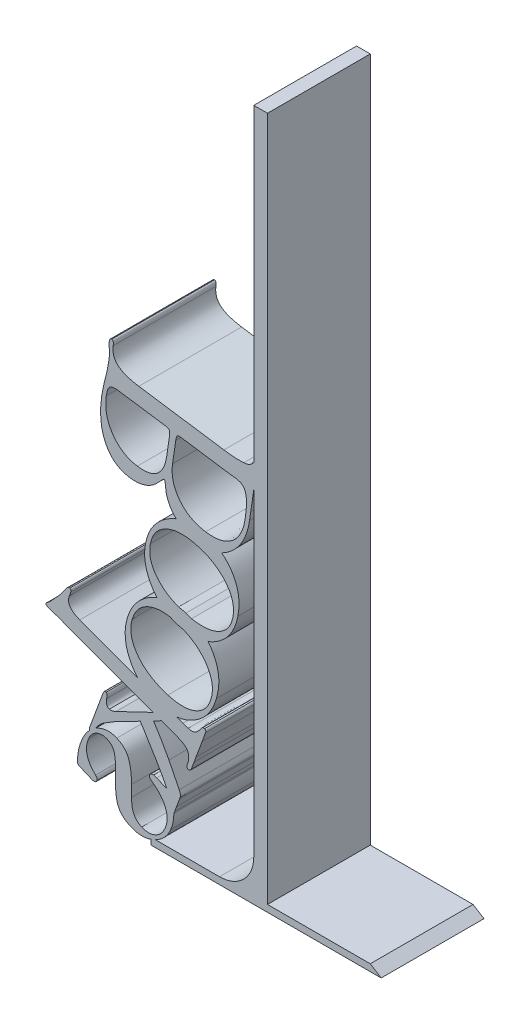
from build123d import *

# Parameters (mm, degrees)
BOSS_EXTRU_1_DEPTH = 30
BOSS_EXTRU_2_DEPTH = 30
CONG_1_R           = 10


with BuildPart() as part:
    # Esquisse1 → Boss.-Extru.1 (new body)
    with BuildSketch(Plane.XY):
        Polygon((0, 0), (37.189024069, 0), (34, 2), (4, 2), (4, 202), (0, 202), (0, 2), (-30, 2), (-30, 0), align=None)
    extrude(amount=BOSS_EXTRU_1_DEPTH)

    # Esquisse3 → Boss.-Extru.2 (add)
    # profile 1 of 5: a face of its own
    with BuildSketch(Plane.XY):
        with BuildLine():
            add(Edge.make_bspline(
                [(-50.119999035, 16.68534549), (-50.282082733, 16.293399286), (-50.595925094, 15.534474581), (-50.938660564, 14.394068336), (-51.203113741, 13.31291377), (-51.286389448, 12.602862585), (-51.326645377, 12.259619995)],
                knots=[0, 0, 0, 0, 1.104514137, 2.138668663, 3.100222345, 4, 4, 4, 4], degree=3))
            Line((-51.326645377, 12.259619995), (-51.501027505, 10.736615205))
            add(Edge.make_bspline(
                [(-51.501027505, 10.736615205), (-51.504554326, 10.592889791), (-51.510980035, 10.331028577), (-51.435333427, 9.973711105), (-51.264410087, 9.695330692), (-51.09112563, 9.596303894), (-51.005850834, 9.54757194)],
                knots=[0, 0, 0, 0, 1.251937487, 2.280973562, 3.154052059, 4, 4, 4, 4], degree=3))
            Line((-51.005850834, 9.54757194), (-50.517964503, 9.346357629))
            add(Edge.make_bspline(
                [(-50.517964503, 9.346357629), (-50.380045017, 9.285943004), (-50.10041353, 9.163452471), (-49.818764175, 9.045675312), (-49.676029556, 8.985988054)],
                knots=[0, 0, 0, 0, 0.986437454, 2, 2, 2, 2], degree=3))
            Line((-49.676029556, 8.985988054), (-48.499937878, 8.486880165))
            add(Edge.make_bspline(
                [(-48.499937878, 8.486880165), (-48.299790457, 8.39848823), (-47.920452322, 8.230959557), (-47.538007585, 8.070653097), (-47.357349383, 7.994927968)],
                knots=[0, 0, 0, 0, 1.055245452, 2, 2, 2, 2], degree=3))
            add(Edge.make_bspline(
                [(-47.357349383, 7.994927968), (-47.179889274, 7.930174771), (-46.863267099, 7.814642901), (-46.37656504, 7.798430686), (-45.981561775, 8.022529158), (-45.835921531, 8.268562161), (-45.759637283, 8.39743068)],
                knots=[0, 0, 0, 0, 1.219013251, 2.174948671, 3.04406458, 4, 4, 4, 4], degree=3))
            add(Edge.make_bspline(
                [(-45.759637283, 8.39743068), (-45.729953475, 8.48391235), (-45.668561112, 8.662774648), (-45.745872642, 8.974150701), (-45.900986107, 9.310633299), (-46.077124366, 9.522983942), (-46.173496201, 9.639168928)],
                knots=[0, 0, 0, 0, 0.780026984, 1.613259994, 2.694125199, 4, 4, 4, 4], degree=3))
            add(Edge.make_bspline(
                [(-46.173496201, 9.639168928), (-46.482738582, 9.939793105), (-47.076274753, 10.516788156), (-47.798191148, 11.479954186), (-48.341613787, 12.466629019), (-48.692232883, 13.489868271), (-48.855669751, 14.542814144), (-48.832648893, 15.62420075), (-48.619749287, 16.733942014), (-48.345410588, 17.451808786), (-48.203626365, 17.82281799)],
                knots=[0, 0, 0, 0, 1.138726599, 2.185584729, 3.168938811, 4.105254725, 5.029930041, 5.971323709, 6.951535848, 8, 8, 8, 8], degree=3))
            add(Edge.make_bspline(
                [(-48.203626365, 17.82281799), (-48.068498438, 18.106484848), (-47.807675032, 18.654017524), (-47.267979095, 19.365288265), (-46.640072106, 19.948703016), (-45.91423927, 20.363796437), (-45.148015441, 20.651258508), (-44.349081637, 20.723201047), (-43.539152222, 20.667268301), (-43.030226056, 20.472727846), (-42.76811349, 20.372533552)],
                knots=[0, 0, 0, 0, 1.119556932, 2.160964479, 3.168212037, 4.158551389, 5.130241561, 6.064749018, 7.003286457, 8, 8, 8, 8], degree=3))
            add(Edge.make_bspline(
                [(-42.76811349, 20.372533552), (-42.50355616, 20.24140882), (-41.987763201, 19.985762101), (-41.366554473, 19.375417489), (-40.900718948, 18.632328609), (-40.663313823, 17.894947979), (-40.553822271, 17.222711755), (-40.45894146, 16.629484244), (-40.413715389, 15.954076742), (-40.346128469, 15.202129167), (-40.321973611, 14.369744564), (-40.320005929, 13.460108764), (-40.3032265, 12.472265334), (-40.321674865, 11.787042299), (-40.331259913, 11.431027265)],
                knots=[0, 0, 0, 0, 1.073847664, 2.093622063, 3.13628929, 4.255159849, 4.897600423, 5.62733423, 6.450362783, 7.371228827, 8.387907505, 9.493754878, 10.697853257, 12, 12, 12, 12], degree=3))
            add(Edge.make_bspline(
                [(-40.331259913, 11.431027265), (-40.340562173, 11.079501855), (-40.358518013, 10.400964174), (-40.344342378, 9.419041524), (-40.296836897, 8.506006031), (-40.215509863, 7.661645265), (-40.100858472, 6.882876856), (-39.943687692, 6.175575059), (-39.748615816, 5.538651635), (-39.461000817, 4.77840835), (-38.949449273, 3.919721319), (-38.122834137, 3.026533204), (-37.086993241, 2.251003784), (-36.2821333, 1.878136125), (-35.862243347, 1.683613605)],
                knots=[0, 0, 0, 0, 1.091810361, 2.107484833, 3.048367522, 3.929971846, 4.740530701, 5.491118865, 6.177284609, 6.807462583, 8.012022279, 9.25179771, 10.566281569, 12, 12, 12, 12], degree=3))
            add(Edge.make_bspline(
                [(-35.862243347, 1.683613605), (-35.587941077, 1.575134305), (-35.047670664, 1.361471632), (-34.212433261, 1.154394074), (-33.377537114, 1.022040427), (-32.535056548, 0.996049375), (-31.68616506, 1.046365311), (-30.836820627, 1.211711012), (-29.983592664, 1.456875029), (-29.136769014, 1.786455276), (-28.312027677, 2.18514399), (-27.551799603, 2.672147859), (-26.835463087, 3.196767103), (-26.193683812, 3.802626812), (-25.607132103, 4.463851466), (-25.084083785, 5.192932072), (-24.613538342, 5.975599632), (-24.359591469, 6.536941779), (-24.231455323, 6.820182989)],
                knots=[0, 0, 0, 0, 1.001392587, 1.972359858, 2.917388064, 3.869012979, 4.830990174, 5.801181602, 6.802805537, 7.844402342, 8.885943535, 9.909816421, 10.908428644, 11.898886892, 12.90270598, 13.907793756, 14.944317593, 16, 16, 16, 16], degree=3))
            add(Edge.make_bspline(
                [(-24.231455323, 6.820182989), (-24.064520153, 7.253243842), (-23.720914897, 8.144619728), (-23.452387978, 9.605323266), (-23.284219076, 11.179296499), (-23.312162466, 12.270656657), (-23.32662712, 12.835589785)],
                knots=[0, 0, 0, 0, 0.906508865, 1.865881291, 2.895291943, 4, 4, 4, 4], degree=3))
            add(Edge.make_bspline(
                [(-23.32662712, 12.835589785), (-23.330567315, 12.961083168), (-23.337601404, 13.18511567), (-23.333065627, 13.48057681), (-23.324662465, 13.697465755), (-23.297149921, 13.811903149), (-23.286452935, 13.856396859)],
                knots=[0, 0, 0, 0, 1.469844638, 2.623986742, 3.465000626, 4, 4, 4, 4], degree=3))
            Line((-23.286452935, 13.856396859), (-23.040729275, 14.666228793))
            add(Edge.make_bspline(
                [(-23.040729275, 14.666228793), (-23.010542233, 14.77934117), (-22.954960712, 14.987607939), (-23.000597061, 15.303378564), (-23.160540141, 15.576093138), (-23.341166535, 15.683166398), (-23.436621545, 15.739751036)],
                knots=[0, 0, 0, 0, 1.103361711, 2.031551157, 2.959740603, 4, 4, 4, 4], degree=3))
            Line((-23.436621545, 15.739751036), (-24.672913942, 16.259800938))
            Line((-24.672913942, 16.259800938), (-28.341482299, 17.819425581))
            Line((-28.341482299, 17.819425581), (-29.217970559, 18.106333182))
            add(Edge.make_bspline(
                [(-29.217970559, 18.106333182), (-29.347343391, 18.124486302), (-29.58846873, 18.158320122), (-29.937369791, 18.095202108), (-30.213493994, 17.89730938), (-30.322823127, 17.70934882), (-30.380141268, 17.610806467)],
                knots=[0, 0, 0, 0, 1.136396999, 2.118018967, 3.013331099, 4, 4, 4, 4], degree=3))
            add(Edge.make_bspline(
                [(-30.380141268, 17.610806467), (-30.418319639, 17.500634164), (-30.492628805, 17.286198299), (-30.433867083, 16.925437704), (-30.204861298, 16.598237719), (-29.98662863, 16.419452119), (-29.866122841, 16.320728586)],
                knots=[0, 0, 0, 0, 0.910847748, 1.772845061, 2.770188407, 4, 4, 4, 4], degree=3))
            add(Edge.make_bspline(
                [(-29.866122841, 16.320728586), (-29.397901029, 15.979014218), (-28.496873381, 15.321432522), (-27.338026784, 14.183438244), (-26.435606666, 12.955221303), (-25.767165449, 11.666197103), (-25.369884225, 10.328844389), (-25.237121159, 8.977790076), (-25.396192934, 7.626919764), (-25.706119497, 6.776610429), (-25.863720736, 6.344218303)],
                knots=[0, 0, 0, 0, 1.186247006, 2.282767106, 3.311218195, 4.29612909, 5.242135699, 6.150931495, 7.059727291, 8, 8, 8, 8], degree=3))
            add(Edge.make_bspline(
                [(-25.863720736, 6.344218303), (-26.03048073, 5.98998909), (-26.353091168, 5.304704575), (-27.029092215, 4.420661911), (-27.822537545, 3.707209947), (-28.731227121, 3.188552422), (-29.702609843, 2.852943665), (-30.714895814, 2.74435649), (-31.742050704, 2.846080679), (-32.391794047, 3.09008854), (-32.724549378, 3.215053139)],
                knots=[0, 0, 0, 0, 1.109636964, 2.146680737, 3.137414998, 4.121590749, 5.099495172, 6.035396231, 6.993860599, 8, 8, 8, 8], degree=3))
            add(Edge.make_bspline(
                [(-32.724549378, 3.215053139), (-32.974620886, 3.334470203), (-33.464577198, 3.568439858), (-34.100802199, 4.073587483), (-34.623810802, 4.68596699), (-35.054294546, 5.398649859), (-35.350614102, 6.231472079), (-35.561448081, 7.160608792), (-35.660276104, 8.198242819), (-35.639510464, 8.921656756), (-35.628643413, 9.30023293)],
                knots=[0, 0, 0, 0, 0.918393831, 1.799376739, 2.674306443, 3.582882783, 4.548696632, 5.597179236, 6.742558518, 8, 8, 8, 8], degree=3))
            Line((-35.628643413, 9.30023293), (-35.708614896, 12.445897139))
            add(Edge.make_bspline(
                [(-35.708614896, 12.445897139), (-35.707408553, 12.78868944), (-35.705072698, 13.452441535), (-35.758421865, 14.41869131), (-35.829900057, 15.318699238), (-35.93383684, 16.158807283), (-36.06718184, 16.930497715), (-36.236887657, 17.640373744), (-36.421835284, 18.289673338), (-36.734783331, 19.053019546), (-37.202371416, 19.921736409), (-37.973383402, 20.795239506), (-38.899355173, 21.536407953), (-39.62033437, 21.879816242), (-39.991273787, 22.056497721)],
                knots=[0, 0, 0, 0, 1.096348091, 2.122869565, 3.094523592, 3.984108865, 4.829981453, 5.597999407, 6.318572389, 6.986506192, 8.235027503, 9.452915801, 10.689540654, 12, 12, 12, 12], degree=3))
            add(Edge.make_bspline(
                [(-39.991273787, 22.056497721), (-40.223225688, 22.149105792), (-40.679131358, 22.331128636), (-41.39356515, 22.486586835), (-42.105152077, 22.586025558), (-42.823180581, 22.575532889), (-43.543636766, 22.492246475), (-44.269100769, 22.316807092), (-44.998265768, 22.054868634), (-45.724234497, 21.715265661), (-46.43178688, 21.308444261), (-47.092240949, 20.816672058), (-47.716994539, 20.278847408), (-48.293811735, 19.676309456), (-48.81749229, 19.013255611), (-49.310822933, 18.300179496), (-49.740600714, 17.515843689), (-49.992137106, 16.96523366), (-50.119999035, 16.68534549)],
                knots=[0, 0, 0, 0, 0.9384291, 1.844499415, 2.743721265, 3.637394757, 4.538668728, 5.468884514, 6.439691688, 7.45009295, 8.482270654, 9.505598982, 10.544432646, 11.58217136, 12.639378486, 13.721824009, 14.841948974, 16, 16, 16, 16], degree=3))
        make_face()
    # profile 2 of 5: a face of its own
    with BuildSketch(Plane.XY):
        with BuildLine():
            Line((-29.395199725, 33.849485162), (-40.180090759, 28.6880927))
            add(Edge.make_bspline(
                [(-40.180090759, 28.6880927), (-40.387877739, 28.596386543), (-40.7687712, 28.428280363), (-41.308637334, 28.268784822), (-41.771705256, 28.198762451), (-42.03773676, 28.261458513), (-42.158758151, 28.289979814)],
                knots=[0, 0, 0, 0, 1.320543319, 2.420682545, 3.28154676, 4, 4, 4, 4], degree=3))
            add(Edge.make_bspline(
                [(-42.158758151, 28.289979814), (-42.325290121, 28.372619075), (-42.661530194, 28.53947371), (-42.955822358, 29.087702524), (-43.048207895, 29.783049265), (-42.982631912, 30.289883441), (-42.945960552, 30.573314932)],
                knots=[0, 0, 0, 0, 0.830302397, 1.676440502, 2.70062051, 4, 4, 4, 4], degree=3))
            add(Edge.make_bspline(
                [(-42.945960552, 30.573314932), (-42.912327114, 30.772323421), (-42.853788699, 31.11869425), (-42.856363784, 31.56423838), (-42.908927134, 31.914284481), (-43.06148531, 32.022286309), (-43.125735518, 32.067771515)],
                knots=[0, 0, 0, 0, 1.514154993, 2.635360548, 3.425279115, 4, 4, 4, 4], degree=3))
            add(Edge.make_bspline(
                [(-43.125735518, 32.067771515), (-43.216834004, 32.090635822), (-43.392066327, 32.134616417), (-43.66615677, 32.036935083), (-43.859259357, 31.784698089), (-43.941630479, 31.577953985), (-43.98881996, 31.459512633)],
                knots=[0, 0, 0, 0, 0.92291914, 1.775279399, 2.725482811, 4, 4, 4, 4], degree=3))
            add(Edge.make_bspline(
                [(-43.98881996, 31.459512633), (-44.023756621, 31.36136312), (-44.103704515, 31.136761029), (-44.241282581, 30.755125879), (-44.416606196, 30.284938951), (-44.547079398, 29.941296705), (-44.61818138, 29.754027254)],
                knots=[0, 0, 0, 0, 0.687688215, 1.573682902, 2.677767137, 4, 4, 4, 4], degree=3))
            add(Edge.make_bspline(
                [(-44.61818138, 29.754027254), (-44.681829065, 29.581066106), (-44.827810408, 29.184365096), (-45.066621179, 28.511285077), (-45.369096614, 27.690830466), (-45.591109997, 27.094823615), (-45.711379816, 26.771952824)],
                knots=[0, 0, 0, 0, 0.696308126, 1.597041536, 2.698261442, 4, 4, 4, 4], degree=3))
            add(Edge.make_bspline(
                [(-45.711379816, 26.771952824), (-45.882860917, 26.311040558), (-46.197884369, 25.46431067), (-46.626321812, 24.302848537), (-46.976020569, 23.365355486), (-47.179836641, 22.812812707), (-47.267880292, 22.574127489)],
                knots=[0, 0, 0, 0, 1.318115353, 2.421475291, 3.318115216, 4, 4, 4, 4], degree=3))
            add(Edge.make_bspline(
                [(-47.267880292, 22.574127489), (-47.334388897, 22.391548919), (-47.458147739, 22.05180773), (-47.633408756, 21.587994184), (-47.770301348, 21.202927507), (-47.854056531, 20.976524567), (-47.891241042, 20.876009203)],
                knots=[0, 0, 0, 0, 1.289034595, 2.398628399, 3.289044351, 4, 4, 4, 4], degree=3))
            add(Edge.make_bspline(
                [(-47.891241042, 20.876009203), (-47.924136959, 20.779911206), (-47.981961326, 20.610990364), (-47.974705915, 20.367092952), (-47.894169188, 20.161325633), (-47.77514215, 20.09265466), (-47.712948441, 20.056772876)],
                knots=[0, 0, 0, 0, 1.297017385, 2.279894238, 3.101214661, 4, 4, 4, 4], degree=3))
            add(Edge.make_bspline(
                [(-47.712948441, 20.056772876), (-47.625022958, 20.037146628), (-47.425254423, 19.992555384), (-47.110535816, 20.200666643), (-46.788605518, 20.534317792), (-46.588071402, 20.834861032), (-46.472891765, 21.00748234)],
                knots=[0, 0, 0, 0, 0.624885338, 1.419752539, 2.517997972, 4, 4, 4, 4], degree=3))
            add(Edge.make_bspline(
                [(-46.472891765, 21.00748234), (-46.248506717, 21.34715357), (-45.823107756, 21.991117106), (-45.109562604, 22.824925156), (-44.417635019, 23.525533137), (-43.909625954, 23.876852198), (-43.669689645, 24.042782699)],
                knots=[0, 0, 0, 0, 1.172418655, 2.222722428, 3.160579112, 4, 4, 4, 4], degree=3))
            Line((-43.669689645, 24.042782699), (-41.151316433, 25.569904269))
            Line((-41.151316433, 25.569904269), (-39.975604226, 26.291163893))
            Line((-39.975604226, 26.291163893), (-33.12933708, 29.746491267))
            Line((-33.12933708, 29.746491267), (-31.889590115, 27.793070416))
            add(Edge.make_bspline(
                [(-31.889590115, 27.793070416), (-31.438911005, 27.071959531), (-30.581053242, 25.69934084), (-29.374222857, 23.735632059), (-28.306495372, 21.974116907), (-27.386444119, 20.411375614), (-26.630001802, 19.040345869), (-25.996559449, 17.883223753), (-25.515514477, 16.923080795), (-25.169186717, 16.120627014), (-24.939505233, 15.399633243), (-24.775296844, 14.691393882), (-24.690220869, 13.955690934), (-24.667419863, 13.194473059), (-24.71041353, 12.404407778), (-24.816337305, 11.58559708), (-24.985953163, 10.741511236), (-25.148307744, 10.180362762), (-25.231099289, 9.894209156)],
                knots=[0, 0, 0, 0, 2.05968914, 3.920572919, 5.582737025, 7.048973651, 8.31255767, 9.375355501, 10.243894575, 10.913118651, 11.489756907, 12.074452628, 12.671252454, 13.280350674, 13.917129829, 14.585561975, 15.278717558, 16, 16, 16, 16], degree=3))
            add(Edge.make_bspline(
                [(-25.231099289, 9.894209156), (-25.263029574, 9.777704852), (-25.319377135, 9.572109021), (-25.323973922, 9.279826007), (-25.219106965, 9.039178222), (-25.076415887, 8.97175394), (-25.005039833, 8.938027379)],
                knots=[0, 0, 0, 0, 1.317215301, 2.32449759, 3.161890475, 4, 4, 4, 4], degree=3))
            add(Edge.make_bspline(
                [(-25.005039833, 8.938027379), (-24.895752381, 8.910895284), (-24.686797448, 8.859019384), (-24.352307652, 8.972538345), (-24.110469035, 9.278632918), (-24.000842852, 9.532106407), (-23.939002575, 9.67509114)],
                knots=[0, 0, 0, 0, 0.907607616, 1.735323542, 2.722492984, 4, 4, 4, 4], degree=3))
            Line((-23.939002575, 9.67509114), (-23.065038096, 12.02692135))
            Line((-23.065038096, 12.02692135), (-22.569296334, 13.387816247))
            add(Edge.make_bspline(
                [(-22.569296334, 13.387816247), (-22.46482066, 13.666333397), (-22.276975241, 14.167102325), (-22.028502476, 14.834460229), (-21.841942901, 15.329332449), (-21.74424384, 15.603952407), (-21.70596677, 15.711544507)],
                knots=[0, 0, 0, 0, 1.439965992, 2.589033479, 3.447203862, 4, 4, 4, 4], degree=3))
            add(Edge.make_bspline(
                [(-21.70596677, 15.711544507), (-21.664073157, 15.82847748), (-21.589410446, 16.036875178), (-21.512931815, 16.244612964), (-21.47936572, 16.335788058)],
                knots=[0, 0, 0, 0, 1.122209831, 2, 2, 2, 2], degree=3))
            add(Edge.make_bspline(
                [(-21.47936572, 16.335788058), (-21.447751783, 16.461408207), (-21.38201887, 16.722602448), (-21.4068408, 17.156956996), (-21.535479224, 17.627822818), (-21.683019421, 17.941911366), (-21.762041489, 18.110136211)],
                knots=[0, 0, 0, 0, 0.839160036, 1.744813793, 2.792129317, 4, 4, 4, 4], degree=3))
            Line((-21.762041489, 18.110136211), (-24.767621736, 24.124392214))
            add(Edge.make_bspline(
                [(-24.767621736, 24.124392214), (-24.879042762, 24.343022442), (-25.118131851, 24.812162816), (-25.520269324, 25.550383751), (-25.973464044, 26.378589561), (-26.504059981, 27.285528125), (-27.094160776, 28.279931685), (-27.754951687, 29.353059342), (-28.468184398, 30.516013704), (-28.97098632, 31.315599516), (-29.23277585, 31.73191295)],
                knots=[0, 0, 0, 0, 0.667359701, 1.43203153, 2.286222551, 3.234952003, 4.28957761, 5.431105702, 6.662476009, 8, 8, 8, 8], degree=3))
            Line((-29.23277585, 31.73191295), (-26.981164948, 32.961617945))
            Line((-26.981164948, 32.961617945), (-22.404646511, 31.268229989))
            add(Edge.make_bspline(
                [(-22.404646511, 31.268229989), (-22.028562268, 31.117045774), (-21.333860107, 30.837778553), (-20.423030348, 30.321649113), (-19.72975314, 29.753207905), (-19.251436221, 29.105928105), (-19.006055762, 28.364501728), (-18.951240447, 27.531076884), (-19.091405473, 26.589873954), (-19.310657124, 25.952009997), (-19.428592608, 25.608902912)],
                knots=[0, 0, 0, 0, 1.303259366, 2.407378435, 3.35536506, 4.168735855, 4.960561286, 5.832774521, 6.834249202, 8, 8, 8, 8], degree=3))
            add(Edge.make_bspline(
                [(-19.428592608, 25.608902912), (-19.464415557, 25.487883542), (-19.528349203, 25.271898824), (-19.542944545, 24.961712494), (-19.422990422, 24.709911325), (-19.273437866, 24.636657721), (-19.197067458, 24.599250084)],
                knots=[0, 0, 0, 0, 1.302053624, 2.323790684, 3.14402807, 4, 4, 4, 4], degree=3))
            add(Edge.make_bspline(
                [(-19.197067458, 24.599250084), (-19.092049337, 24.566825273), (-18.893650236, 24.505568671), (-18.585084896, 24.601875094), (-18.34787945, 24.842456699), (-18.259206935, 25.058677357), (-18.20957388, 25.17970349)],
                knots=[0, 0, 0, 0, 0.989224264, 1.8688318, 2.807111916, 4, 4, 4, 4], degree=3))
            add(Edge.make_bspline(
                [(-18.20957388, 25.17970349), (-18.185711693, 25.249913516), (-18.115753147, 25.455753462), (-17.952489545, 25.852432612), (-17.744196893, 26.456728341), (-17.569472001, 26.920734307), (-17.469229059, 27.186943217)],
                knots=[0, 0, 0, 0, 0.415847753, 1.219171743, 2.40458677, 4, 4, 4, 4], degree=3))
            add(Edge.make_bspline(
                [(-17.469229059, 27.186943217), (-17.436062677, 27.278266063), (-17.358448867, 27.491973851), (-17.216747053, 27.857104314), (-17.052080298, 28.320541624), (-16.924665775, 28.658934047), (-16.855136801, 28.843591791)],
                knots=[0, 0, 0, 0, 0.659876692, 1.544200524, 2.659892005, 4, 4, 4, 4], degree=3))
            add(Edge.make_bspline(
                [(-16.855136801, 28.843591791), (-16.737692876, 29.164313034), (-16.515549995, 29.770950975), (-16.191535579, 30.626140897), (-15.928110423, 31.388371969), (-15.664314901, 32.037273792), (-15.477582123, 32.599304148), (-15.298714068, 33.047921496), (-15.176555988, 33.402124192), (-15.099714927, 33.602240719), (-15.067401028, 33.686395533)],
                knots=[0, 0, 0, 0, 1.587854254, 3.003395192, 4.251418262, 5.336342401, 6.258474726, 7.00348015, 7.580934449, 8, 8, 8, 8], degree=3))
            add(Edge.make_bspline(
                [(-15.067401028, 33.686395533), (-14.938713853, 34.042474188), (-14.712324625, 34.668895365), (-14.399650356, 35.474919748), (-14.207934541, 36.039364107), (-14.097390375, 36.327422206), (-14.057915494, 36.430286606)],
                knots=[0, 0, 0, 0, 1.553942734, 2.733729252, 3.547819759, 4, 4, 4, 4], degree=3))
            add(Edge.make_bspline(
                [(-14.057915494, 36.430286606), (-14.029935226, 36.519107467), (-13.980132431, 36.677201996), (-14.017008753, 36.922215057), (-14.162792823, 37.119977185), (-14.314134446, 37.184938355), (-14.395254825, 37.219758087)],
                knots=[0, 0, 0, 0, 1.129225911, 2.009938166, 2.933310173, 4, 4, 4, 4], degree=3))
            add(Edge.make_bspline(
                [(-14.395254825, 37.219758087), (-14.474879105, 37.240501219), (-14.626156692, 37.279910944), (-14.86118025, 37.270924544), (-15.064408221, 37.157040566), (-15.168053974, 37.045241739), (-15.22239322, 36.986628011)],
                knots=[0, 0, 0, 0, 1.06632971, 2.02591201, 2.965027986, 4, 4, 4, 4], degree=3))
            Line((-15.22239322, 36.986628011), (-15.98964748, 35.969434178))
            add(Edge.make_bspline(
                [(-15.98964748, 35.969434178), (-16.094083061, 35.837516153), (-16.294389404, 35.584498774), (-16.650368529, 35.277016025), (-17.016893705, 35.029578117), (-17.409027025, 34.866194388), (-17.817840883, 34.785332352), (-18.24236981, 34.770776757), (-18.691797734, 34.822743138), (-18.985049084, 34.925747615), (-19.136956459, 34.979105049)],
                knots=[0, 0, 0, 0, 1.126139808, 2.159924269, 3.140842375, 4.081840271, 4.987648142, 5.920940705, 6.923024776, 8, 8, 8, 8], degree=3))
            Line((-19.136956459, 34.979105049), (-20.686366458, 35.469084645))
            Line((-20.686366458, 35.469084645), (-21.699938025, 35.804471225))
            Line((-21.699938025, 35.804471225), (-50.784862421, 46.541520776))
            add(Edge.make_bspline(
                [(-50.784862421, 46.541520776), (-51.105945545, 46.670758193), (-51.710288944, 46.914009159), (-52.516074689, 47.364756303), (-53.161724716, 47.865391368), (-53.641545177, 48.423412294), (-53.953619895, 49.036079725), (-54.080070338, 49.703832802), (-54.039514842, 50.41365186), (-53.894995565, 50.878053966), (-53.819382684, 51.121030419)],
                knots=[0, 0, 0, 0, 1.327427085, 2.498486331, 3.53179592, 4.447277462, 5.301385963, 6.138721628, 7.026174063, 8, 8, 8, 8], degree=3))
            Line((-53.819382684, 51.121030419), (-53.440090018, 52.23364202))
            add(Edge.make_bspline(
                [(-53.440090018, 52.23364202), (-53.407629141, 52.333926813), (-53.349505688, 52.513493697), (-53.360118573, 52.782612086), (-53.485144431, 52.999124658), (-53.625381472, 53.069202602), (-53.698054221, 53.105517949)],
                knots=[0, 0, 0, 0, 1.227654208, 2.198200078, 3.066282693, 4, 4, 4, 4], degree=3))
            add(Edge.make_bspline(
                [(-53.698054221, 53.105517949), (-53.78061469, 53.123699059), (-53.94842365, 53.160653224), (-54.209967506, 53.04857093), (-54.46739306, 52.852473038), (-54.613693, 52.663602694), (-54.695647739, 52.557800739)],
                knots=[0, 0, 0, 0, 0.814904237, 1.656340302, 2.687121687, 4, 4, 4, 4], degree=3))
            Line((-54.695647739, 52.557800739), (-55.613453713, 51.295591431))
            add(Edge.make_bspline(
                [(-55.613453713, 51.295591431), (-55.776488059, 51.060917173), (-56.084166029, 50.618040556), (-56.548433875, 50.023052205), (-56.961444925, 49.520790856), (-57.236132439, 49.234851744), (-57.361549964, 49.104296936)],
                knots=[0, 0, 0, 0, 1.221506236, 2.305223222, 3.226194502, 4, 4, 4, 4], degree=3))
            Line((-57.361549964, 49.104296936), (-59.108337762, 47.230560924))
            add(Edge.make_bspline(
                [(-59.108337762, 47.230560924), (-59.29597756, 47.0300286), (-59.610483955, 46.693912811), (-59.979610226, 46.419695848), (-60.128509564, 46.309081331)],
                knots=[0, 0, 0, 0, 1.193233588, 2, 2, 2, 2], degree=3))
            add(Edge.make_bspline(
                [(-60.128509564, 46.309081331), (-60.243850771, 46.224052736), (-60.436736961, 46.081858613), (-60.565140356, 45.880765016), (-60.616761673, 45.799920453)],
                knots=[0, 0, 0, 0, 1.195950903, 2, 2, 2, 2], degree=3))
            add(Edge.make_bspline(
                [(-60.616761673, 45.799920453), (-60.631948559, 45.730749768), (-60.663174584, 45.588526695), (-60.531706719, 45.370835513), (-60.287940895, 45.206082004), (-60.084201046, 45.1230514), (-59.968695976, 45.075979334)],
                knots=[0, 0, 0, 0, 0.760457235, 1.563589588, 2.618739738, 4, 4, 4, 4], degree=3))
            Line((-59.968695976, 45.075979334), (-58.764411435, 44.658781251))
            Line((-58.764411435, 44.658781251), (-57.511290088, 44.226314006))
            Line((-57.511290088, 44.226314006), (-29.395199725, 33.849485162))
        make_face()
    # profile 3 of 5: a face of its own
    with BuildSketch(Plane.XY):
        with BuildLine():
            add(Edge.make_bspline(
                [(-36.918860317, 53.946748977), (-37.042557818, 53.489000432), (-37.28601082, 52.588090907), (-37.495520088, 51.216390399), (-37.571511324, 49.860353708), (-37.509774246, 48.521072013), (-37.325694498, 47.197188606), (-36.999945124, 45.886373433), (-36.538958103, 44.589600861), (-35.956181247, 43.320972169), (-35.271072453, 42.115542408), (-34.492353908, 41.00186752), (-33.616759452, 40.012035667), (-32.679139458, 39.113693384), (-31.648447453, 38.334702067), (-30.531794773, 37.677096867), (-29.339676138, 37.117278863), (-28.499442144, 36.843092104), (-28.07451055, 36.704427617)],
                knots=[0, 0, 0, 0, 1.056933008, 2.080183599, 3.088301019, 4.081657649, 5.065803133, 6.064845509, 7.088754287, 8.131139035, 9.174767794, 10.177524697, 11.156076377, 12.117703317, 13.069471436, 14.030241716, 15.003834012, 16, 16, 16, 16], degree=3))
            add(Edge.make_bspline(
                [(-28.07451055, 36.704427617), (-27.607037969, 36.578418028), (-26.689531984, 36.331099669), (-25.299297977, 36.117936256), (-23.934998849, 36.051739001), (-22.59575306, 36.122333308), (-21.282881635, 36.338628664), (-19.990396293, 36.678698526), (-18.731365545, 37.184609476), (-17.510930294, 37.816129068), (-16.351354035, 38.566784352), (-15.268317486, 39.410475647), (-14.291393353, 40.366075939), (-13.410528514, 41.418115421), (-12.628047026, 42.570251138), (-11.93968119, 43.81975125), (-11.359909587, 45.170358606), (-11.053342895, 46.117127773), (-10.897508366, 46.59839117)],
                knots=[0, 0, 0, 0, 1.046525377, 2.054009873, 3.034779403, 3.996148322, 4.948666677, 5.907910102, 6.880633019, 7.876877099, 8.87559083, 9.864127915, 10.841062554, 11.825366057, 12.826965063, 13.848440982, 14.906315671, 16, 16, 16, 16], degree=3))
            add(Edge.make_bspline(
                [(-10.897508366, 46.59839117), (-10.768104524, 47.078441507), (-10.514336459, 48.019846671), (-10.284369786, 49.440189196), (-10.179418428, 50.826958389), (-10.204354535, 52.18505933), (-10.373520376, 53.507569051), (-10.670500383, 54.79981429), (-11.100291952, 56.059417302), (-11.658009655, 57.279614425), (-12.324650521, 58.436367342), (-13.103453042, 59.497304816), (-13.974508764, 60.462167099), (-14.948366162, 61.326970168), (-16.01601705, 62.097266095), (-17.188896604, 62.75319985), (-18.452703623, 63.320835443), (-19.347254885, 63.609012384), (-19.804031833, 63.756161675)],
                knots=[0, 0, 0, 0, 1.100376582, 2.157899111, 3.180422777, 4.176631023, 5.16024284, 6.127414586, 7.10802132, 8.102079394, 9.093933043, 10.059093797, 11.010989133, 11.967009488, 12.937937452, 13.920223158, 14.938021598, 16, 16, 16, 16], degree=3))
            add(Edge.make_bspline(
                [(-19.804031833, 63.756161675), (-20.253630684, 63.875457242), (-21.142522477, 64.111313828), (-22.492507966, 64.298646461), (-23.829319227, 64.35895588), (-25.148674192, 64.266616474), (-26.455172321, 64.033992686), (-27.743507654, 63.665584655), (-29.022754897, 63.162748955), (-30.266323364, 62.516075178), (-31.45238129, 61.757128738), (-32.549429701, 60.904057265), (-33.541642298, 59.964373207), (-34.431575136, 58.936540486), (-35.215941533, 57.818790705), (-35.900617921, 56.614784839), (-36.469644424, 55.316515331), (-36.767425904, 54.408508606), (-36.918860317, 53.946748977)],
                knots=[0, 0, 0, 0, 1.016377254, 2.00945665, 2.973442935, 3.938001282, 4.895096156, 5.870263196, 6.863463337, 7.895692262, 8.930218873, 9.93863631, 10.929975325, 11.913737116, 12.906550817, 13.911179571, 14.937746914, 16, 16, 16, 16], degree=3))
        make_face()
        with BuildLine():
            add(Edge.make_bspline(
                [(-35.481960237, 54.377561509), (-35.38146107, 54.692741079), (-35.185024487, 55.308793924), (-34.778576588, 56.173399031), (-34.31512231, 56.972583351), (-33.763199012, 57.692065053), (-33.150180179, 58.348446599), (-32.450836842, 58.92027123), (-31.688960221, 59.431800881), (-30.854159062, 59.854607032), (-29.969782254, 60.197581956), (-29.04521921, 60.453184033), (-28.089753201, 60.61821771), (-27.101753171, 60.698325014), (-26.083686464, 60.661412538), (-25.034379613, 60.565181396), (-23.952107627, 60.373239677), (-23.234094058, 60.170370468), (-22.865491206, 60.066224568)],
                knots=[0, 0, 0, 0, 1.019348034, 1.992426911, 2.940066608, 3.863530702, 4.78326696, 5.703936591, 6.6434853, 7.608587582, 8.583625943, 9.564908359, 10.562012708, 11.570442203, 12.616131933, 13.699738416, 14.819126802, 16, 16, 16, 16], degree=3))
            add(Edge.make_bspline(
                [(-22.865491206, 60.066224568), (-22.400957539, 59.919101859), (-21.487041811, 59.629655114), (-20.177648087, 59.094472114), (-18.954703674, 58.477033643), (-17.811908285, 57.793222367), (-16.763052065, 57.022183771), (-15.794539353, 56.187073262), (-14.923698783, 55.264842378), (-14.137871867, 54.287319136), (-13.45964214, 53.262445918), (-12.919302641, 52.209099778), (-12.487887617, 51.152711152), (-12.211449666, 50.079126453), (-12.067326203, 48.998219462), (-12.068678402, 47.909956798), (-12.189725119, 46.811357201), (-12.374144657, 46.091567541), (-12.467712671, 45.726371476)],
                knots=[0, 0, 0, 0, 1.186884254, 2.335056127, 3.441819704, 4.522172868, 5.575736247, 6.609702175, 7.633714206, 8.661557153, 9.662513756, 10.622039216, 11.541894419, 12.436844589, 13.31540923, 14.191530394, 15.082445856, 16, 16, 16, 16], degree=3))
            add(Edge.make_bspline(
                [(-12.467712671, 45.726371476), (-12.566859819, 45.414090086), (-12.760595343, 44.803885961), (-13.156736164, 43.947798664), (-13.626213568, 43.170741952), (-14.159505797, 42.468736078), (-14.762413332, 41.840675993), (-15.437433936, 41.295086658), (-16.185094405, 40.823425769), (-16.996374723, 40.432413875), (-17.865857892, 40.120994463), (-18.779604868, 39.896685833), (-19.732932152, 39.759367465), (-20.725770712, 39.712523208), (-21.75795253, 39.74886792), (-22.832463877, 39.875198533), (-23.945227381, 40.091583832), (-24.690364683, 40.300609996), (-25.071675097, 40.407575321)],
                knots=[0, 0, 0, 0, 1.017876732, 1.988951631, 2.924425216, 3.835693495, 4.724335435, 5.624523239, 6.52729254, 7.466851521, 8.418816149, 9.393628362, 10.387160254, 11.408603072, 12.479810822, 13.594664978, 14.769113704, 16, 16, 16, 16], degree=3))
            add(Edge.make_bspline(
                [(-25.071675097, 40.407575321), (-25.553279299, 40.556782229), (-26.491654057, 40.847502277), (-27.829756216, 41.392284027), (-29.074546783, 41.996103959), (-30.230046024, 42.670077372), (-31.291181429, 43.40904523), (-32.2620185, 44.215205031), (-33.129183434, 45.097242472), (-33.900968609, 46.036300178), (-34.556663551, 47.017729787), (-35.094859479, 48.019687385), (-35.495229069, 49.038745706), (-35.754065502, 50.077999879), (-35.904046354, 51.130872383), (-35.897611604, 52.207127684), (-35.767623765, 53.29795489), (-35.578142956, 54.014058681), (-35.481960237, 54.377561509)],
                knots=[0, 0, 0, 0, 1.242666283, 2.42125519, 3.558150705, 4.651569249, 5.715961928, 6.74311966, 7.758333292, 8.761156592, 9.735854285, 10.663983228, 11.560561621, 12.427538573, 13.29956551, 14.175465273, 15.073844401, 16, 16, 16, 16], degree=3))
        make_face(mode=Mode.SUBTRACT)
    # profile 4 of 5: a face of its own
    with BuildSketch(Plane.XY):
        with BuildLine():
            add(Edge.make_bspline(
                [(-31.570275865, 75.533220496), (-31.650093748, 75.071094038), (-31.807571175, 74.159337388), (-31.879529287, 72.785821), (-31.82327878, 71.437811227), (-31.630536927, 70.117238589), (-31.299194548, 68.827481747), (-30.860454462, 67.556230194), (-30.252572324, 66.324429756), (-29.551527254, 65.119488837), (-28.729946713, 63.995859231), (-27.845681232, 62.958842698), (-26.878146541, 62.045384472), (-25.830962368, 61.262070237), (-24.723034933, 60.572820925), (-23.531985532, 60.020554429), (-22.275559281, 59.570638411), (-21.402296665, 59.374029995), (-20.959992726, 59.274448638)],
                knots=[0, 0, 0, 0, 1.043499551, 2.058782044, 3.055474748, 4.043748357, 5.024139501, 6.01713259, 7.032219111, 8.07752831, 9.117709965, 10.127096745, 11.108628689, 12.073371024, 13.034834065, 14.008480048, 14.991303299, 16, 16, 16, 16], degree=3))
            add(Edge.make_bspline(
                [(-20.959992726, 59.274448638), (-20.475012372, 59.19209126), (-19.524551088, 59.030687816), (-18.102788207, 58.94267596), (-16.720961991, 59.002719061), (-15.377616288, 59.177392484), (-14.074428815, 59.502927276), (-12.811550112, 59.960281737), (-11.593460039, 60.569842077), (-10.419284579, 61.29413927), (-9.325813044, 62.136207849), (-8.317370535, 63.063072773), (-7.438836872, 64.099342641), (-6.64479571, 65.208633217), (-5.981392549, 66.421474597), (-5.404527595, 67.710200254), (-4.948462543, 69.094478414), (-4.737468754, 70.057503882), (-4.629988461, 70.548069311)],
                knots=[0, 0, 0, 0, 1.061997142, 2.081294962, 3.069542284, 4.045663413, 5.002072676, 5.964992098, 6.940753588, 7.938895881, 8.940221302, 9.917540273, 10.891261298, 11.869322194, 12.859060068, 13.871540074, 14.91576195, 16, 16, 16, 16], degree=3))
            add(Edge.make_bspline(
                [(-4.629988461, 70.548069311), (-4.544730272, 71.031780094), (-4.377175782, 71.982397432), (-4.280904449, 73.404207096), (-4.310839812, 74.783444292), (-4.483174449, 76.11789843), (-4.771263086, 77.41331075), (-5.191642049, 78.668405953), (-5.748518885, 79.879760834), (-6.434367475, 81.031230177), (-7.22232318, 82.110917316), (-8.111539248, 83.088802811), (-9.078243814, 83.976840591), (-10.150081479, 84.737850464), (-11.305807683, 85.400595019), (-12.550503483, 85.944245426), (-13.877495118, 86.407559379), (-14.806703531, 86.608322506), (-15.282001672, 86.711014582)],
                knots=[0, 0, 0, 0, 1.085107691, 2.132518482, 3.144245495, 4.130034338, 5.101876237, 6.073465913, 7.050263334, 8.043211374, 9.031483316, 9.999712172, 10.960597675, 11.927331901, 12.899199019, 13.900406202, 14.92603961, 16, 16, 16, 16], degree=3))
            add(Edge.make_bspline(
                [(-15.282001672, 86.711014582), (-15.748363707, 86.788452282), (-16.664751266, 86.940615064), (-18.043340625, 87.01870247), (-19.389659486, 86.948642355), (-20.712313768, 86.75459908), (-22.005180328, 86.408732111), (-23.270689443, 85.931572535), (-24.510269374, 85.323228388), (-25.693587608, 84.570683692), (-26.817133557, 83.724811813), (-27.841432149, 82.786349267), (-28.750801649, 81.769181968), (-29.554777728, 80.679875168), (-30.225771275, 79.501539031), (-30.80497949, 78.255193152), (-31.260017196, 76.925033377), (-31.465991599, 76.00103719), (-31.570275865, 75.533220496)],
                knots=[0, 0, 0, 0, 1.031752934, 2.027363894, 3.007798925, 3.971058345, 4.94097304, 5.924014483, 6.920201746, 7.950284499, 8.98138824, 9.987631139, 10.978329991, 11.956493995, 12.937879829, 13.933971065, 14.95397531, 16, 16, 16, 16], degree=3))
        make_face()
        with BuildLine():
            add(Edge.make_bspline(
                [(-30.187121985, 76.091608671), (-30.113947395, 76.411136077), (-29.97054184, 77.037337121), (-29.64973072, 77.929094146), (-29.266383934, 78.764789921), (-28.770784578, 79.515526018), (-28.22461563, 80.22281393), (-27.568220307, 80.841655168), (-26.8479412, 81.409591271), (-26.049880789, 81.904652026), (-25.187982652, 82.310665452), (-24.282843166, 82.643368515), (-23.338955605, 82.907033508), (-22.346394449, 83.046941434), (-21.317739072, 83.119373252), (-20.248498986, 83.11205787), (-19.137128406, 83.014121002), (-18.389732561, 82.878607821), (-18.007119619, 82.809234815)],
                knots=[0, 0, 0, 0, 1.005968304, 1.971469084, 2.905836535, 3.822255833, 4.728393712, 5.644348176, 6.584571889, 7.542544762, 8.521768887, 9.50566921, 10.502327824, 11.525274908, 12.578264783, 13.667871687, 14.806117963, 16, 16, 16, 16], degree=3))
            add(Edge.make_bspline(
                [(-18.007119619, 82.809234815), (-17.521330861, 82.706348615), (-16.567567333, 82.504349075), (-15.193676257, 82.076053372), (-13.89724129, 81.578008208), (-12.6812536, 80.99645784), (-11.541540973, 80.338686386), (-10.48703516, 79.585236428), (-9.50898166, 78.756186541), (-8.619841218, 77.854930295), (-7.844431196, 76.896265171), (-7.174199408, 75.917588667), (-6.652890362, 74.905473082), (-6.26553956, 73.872167468), (-6.017991733, 72.81536595), (-5.900724196, 71.73868401), (-5.916024, 70.641779918), (-6.032775364, 69.914864932), (-6.091823327, 69.547221698)],
                knots=[0, 0, 0, 0, 1.20254186, 2.360986226, 3.482312061, 4.565003113, 5.623464161, 6.666456847, 7.700632676, 8.726633527, 9.728826011, 10.68464233, 11.595504431, 12.480128391, 13.351877581, 14.218035861, 15.098756977, 16, 16, 16, 16], degree=3))
            add(Edge.make_bspline(
                [(-6.091823327, 69.547221698), (-6.164178672, 69.23083776), (-6.305238097, 68.614035555), (-6.613391427, 67.733424684), (-7.009156454, 66.926069477), (-7.473298546, 66.180118944), (-8.030213018, 65.51327388), (-8.656968109, 64.907383229), (-9.368113033, 64.376730502), (-10.152746314, 63.921056605), (-10.991755434, 63.526348126), (-11.896310763, 63.238249438), (-12.843123889, 63.016045286), (-13.841433171, 62.875121841), (-14.889974235, 62.841711544), (-15.986401335, 62.87116846), (-17.13177781, 62.984981591), (-17.904079255, 63.123251235), (-18.299648978, 63.194072396)],
                knots=[0, 0, 0, 0, 1.00333842, 1.956045414, 2.877725918, 3.779672444, 4.666435678, 5.557894097, 6.470418521, 7.403122013, 8.360651853, 9.332012787, 10.333196834, 11.366457051, 12.44426677, 13.573940066, 14.75738177, 16, 16, 16, 16], degree=3))
            add(Edge.make_bspline(
                [(-18.299648978, 63.194072396), (-18.79802402, 63.300073713), (-19.774173631, 63.507694753), (-21.182001251, 63.926099279), (-22.502773943, 64.415443194), (-23.733959853, 64.97890477), (-24.872372197, 65.624892496), (-25.93598979, 66.327298161), (-26.899863548, 67.124050053), (-27.763541875, 67.987525091), (-28.525828555, 68.891452431), (-29.164702456, 69.835692749), (-29.660735346, 70.813719095), (-30.048365637, 71.813170076), (-30.284855132, 72.846675212), (-30.386106573, 73.908993382), (-30.360663749, 74.998099832), (-30.24547503, 75.723918676), (-30.187121985, 76.091608671)],
                knots=[0, 0, 0, 0, 1.24881498, 2.446009843, 3.596930842, 4.69982922, 5.761471339, 6.803276504, 7.820838067, 8.821579766, 9.793931254, 10.715861789, 11.609698511, 12.477313675, 13.337705711, 14.199778065, 15.088031953, 16, 16, 16, 16], degree=3))
        make_face(mode=Mode.SUBTRACT)
    # profile 5 of 5: a face of its own
    with BuildSketch(Plane.XY):
        with BuildLine():
            Line((-8.715469668, 110.542046066), (-33.555493927, 114.198722244))
            add(Edge.make_bspline(
                [(-33.555493927, 114.198722244), (-33.898586935, 114.252805346), (-34.558440614, 114.356820679), (-35.508460841, 114.549934411), (-36.3782052, 114.785470189), (-37.178054589, 115.047330045), (-37.90170566, 115.336713035), (-38.553438276, 115.655008397), (-39.12385952, 116.012316022), (-39.621976002, 116.397895445), (-40.048676528, 116.814744057), (-40.394888214, 117.27426487), (-40.687518469, 117.757134452), (-40.903675444, 118.282979614), (-41.038844435, 118.845751088), (-41.104922178, 119.442822377), (-41.124968697, 120.07352533), (-41.069499318, 120.500848245), (-41.040900365, 120.721167778)],
                knots=[0, 0, 0, 0, 1.477236386, 2.841095112, 4.120933459, 5.307626278, 6.418901213, 7.433456141, 8.388299802, 9.276380263, 10.108549461, 10.916823639, 11.717201019, 12.504087285, 13.324506589, 14.170088268, 15.056532467, 16, 16, 16, 16], degree=3))
            add(Edge.make_bspline(
                [(-41.040900365, 120.721167778), (-41.018611427, 120.920536711), (-40.979673922, 121.268822864), (-40.998244557, 121.721621385), (-41.147485073, 122.067790759), (-41.341333681, 122.139517206), (-41.432664559, 122.173310791)],
                knots=[0, 0, 0, 0, 1.458643788, 2.548167482, 3.315975797, 4, 4, 4, 4], degree=3))
            add(Edge.make_bspline(
                [(-41.432664559, 122.173310791), (-41.529942692, 122.171415351), (-41.735067799, 122.167418539), (-41.977695101, 121.898010817), (-42.143289587, 121.503914258), (-42.20239584, 121.182518091), (-42.236414713, 120.997537065)],
                knots=[0, 0, 0, 0, 0.716517166, 1.510880772, 2.567376103, 4, 4, 4, 4], degree=3))
            add(Edge.make_bspline(
                [(-42.236414713, 120.997537065), (-42.239725976, 120.929235579), (-42.248473441, 120.748801461), (-42.241874413, 120.403660019), (-42.206384162, 119.917057536), (-42.183903537, 119.542109013), (-42.171254291, 119.331135513)],
                knots=[0, 0, 0, 0, 0.491667184, 1.298852185, 2.480136409, 4, 4, 4, 4], degree=3))
            add(Edge.make_bspline(
                [(-42.171254291, 119.331135513), (-42.148658284, 119.151799169), (-42.09971103, 118.763322507), (-42.109828023, 118.134637111), (-42.16105931, 117.420602051), (-42.226867871, 116.919503776), (-42.261932732, 116.652502932)],
                knots=[0, 0, 0, 0, 0.805729241, 1.74536293, 2.798658803, 4, 4, 4, 4], degree=3))
            add(Edge.make_bspline(
                [(-42.261932732, 116.652502932), (-42.32006285, 116.283866691), (-42.429348557, 115.59082368), (-42.572195379, 114.619774474), (-42.741693858, 113.790594778), (-42.848628515, 113.284118118), (-42.897806703, 113.051194527)],
                knots=[0, 0, 0, 0, 1.224332996, 2.301768879, 3.219000356, 4, 4, 4, 4], degree=3))
            Line((-42.897806703, 113.051194527), (-43.77297614, 109.546663536))
            add(Edge.make_bspline(
                [(-43.77297614, 109.546663536), (-43.8988698, 109.005753501), (-44.142468416, 107.959116714), (-44.312005351, 106.8979936), (-44.393924279, 106.385267168)],
                knots=[0, 0, 0, 0, 1.033615561, 2, 2, 2, 2], degree=3))
            add(Edge.make_bspline(
                [(-44.393924279, 106.385267168), (-44.466982307, 105.816077284), (-44.609634315, 104.704685672), (-44.730762408, 103.070783076), (-44.725344219, 101.513958812), (-44.645358306, 100.039228114), (-44.451689816, 98.645017246), (-44.158702502, 97.333295076), (-43.764061986, 96.100179031), (-43.264365941, 94.956218018), (-42.691484427, 93.897548905), (-42.004009812, 92.967319187), (-41.259875788, 92.129645255), (-40.409566378, 91.428658781), (-39.481339858, 90.838260224), (-38.468907786, 90.368832274), (-37.376608607, 90.008433602), (-36.610751843, 89.870810821), (-36.219679804, 89.800536034)],
                knots=[0, 0, 0, 0, 1.327241097, 2.591551018, 3.785994998, 4.925837503, 6.005125514, 7.037629503, 8.031169933, 8.994516655, 9.92175688, 10.808435559, 11.664160566, 12.506899422, 13.348204262, 14.202077218, 15.081920585, 16, 16, 16, 16], degree=3))
            add(Edge.make_bspline(
                [(-36.219679804, 89.800536034), (-35.813384414, 89.752312507), (-35.015714034, 89.657636366), (-33.830572479, 89.682550848), (-32.697467878, 89.853016145), (-31.61424695, 90.153842345), (-30.582874399, 90.602669996), (-29.606281433, 91.192150528), (-28.680782466, 91.922173325), (-28.125963105, 92.494263213), (-27.841289744, 92.787797943)],
                knots=[0, 0, 0, 0, 1.055441708, 2.072124392, 3.049400627, 4.007290772, 4.966436711, 5.944089222, 6.945128681, 8, 8, 8, 8], degree=3))
            Line((-27.841289744, 92.787797943), (-26.693121048, 93.995188875))
            add(Edge.make_bspline(
                [(-26.693121048, 93.995188875), (-26.601010464, 94.119380546), (-26.460616281, 94.308672455), (-26.234751694, 94.345305176), (-26.157073582, 94.357903701)],
                knots=[0, 0, 0, 0, 1.312170943, 2, 2, 2, 2], degree=3))
            add(Edge.make_bspline(
                [(-26.157073582, 94.357903701), (-26.105105242, 94.318278156), (-25.956446062, 94.204926428), (-25.894393081, 93.822403348), (-25.779888494, 93.30396999), (-25.756572075, 92.878054323), (-25.743161292, 92.633082635)],
                knots=[0, 0, 0, 0, 0.420880894, 1.203960127, 2.391816361, 4, 4, 4, 4], degree=3))
            add(Edge.make_bspline(
                [(-25.743161292, 92.633082635), (-25.715624119, 92.340119476), (-25.661026643, 91.759266497), (-25.481516691, 90.90643184), (-25.223919752, 90.082668618), (-24.910097806, 89.283035772), (-24.51744074, 88.515102245), (-24.04608955, 87.779893328), (-23.510226773, 87.06701258), (-22.898370186, 86.39296053), (-22.231943204, 85.770851814), (-21.53477473, 85.187581163), (-20.781333027, 84.698423785), (-19.999097042, 84.257907722), (-19.182806909, 83.876089569), (-18.320152979, 83.582752787), (-17.429196095, 83.33491321), (-16.815146752, 83.232610116), (-16.50436567, 83.180832737)],
                knots=[0, 0, 0, 0, 0.9882626, 1.959411134, 2.921888526, 3.886247365, 4.84282138, 5.815135759, 6.817794744, 7.836594146, 8.869693381, 9.880174547, 10.886611525, 11.883093616, 12.896261939, 13.909430262, 14.941926195, 16, 16, 16, 16], degree=3))
            add(Edge.make_bspline(
                [(-16.50436567, 83.180832737), (-16.040613413, 83.126077033), (-15.128438871, 83.018375651), (-13.76704155, 83.029460702), (-12.446072559, 83.166671809), (-11.1698604, 83.469450582), (-9.936443143, 83.904054036), (-8.746609634, 84.488269991), (-7.603743864, 85.220826196), (-6.507046948, 86.081524227), (-5.487049497, 87.062534853), (-4.559093862, 88.14011552), (-3.737523559, 89.30783305), (-3.015745827, 90.561328327), (-2.417831587, 91.91181857), (-1.902452064, 93.343906836), (-1.504760434, 94.870277252), (-1.328827302, 95.925877118), (-1.239371126, 96.462614714)],
                knots=[0, 0, 0, 0, 0.989309841, 1.945916675, 2.87998108, 3.799715771, 4.720161221, 5.647635683, 6.603558645, 7.593529294, 8.599027272, 9.599511499, 10.604201776, 11.622203628, 12.661253485, 13.731604959, 14.846596195, 16, 16, 16, 16], degree=3))
            Line((-1.239371126, 96.462614714), (-0.878742993, 98.907569128))
            Line((-0.878742993, 98.907569128), (-0.436905316, 101.852781054))
            Line((-0.436905316, 101.852781054), (-0.06375872, 104.412648646))
            add(Edge.make_bspline(
                [(-0.06375872, 104.412648646), (-0.0042737, 104.813678981), (0.108125326, 105.571439834), (0.273949492, 106.644151014), (0.408568326, 107.58607016), (0.494237097, 108.170673539), (0.533596828, 108.439264197)],
                knots=[0, 0, 0, 0, 1.195130621, 2.258241131, 3.19976487, 4, 4, 4, 4], degree=3))
            add(Edge.make_bspline(
                [(0.533596828, 108.439264197), (0.604172217, 108.899294703), (0.734483191, 109.748698789), (1.015687952, 110.560315203), (1.144594448, 110.932366614)],
                knots=[0, 0, 0, 0, 1.083184113, 2, 2, 2, 2], degree=3))
            add(Edge.make_bspline(
                [(1.144594448, 110.932366614), (1.233445134, 111.160623722), (1.395985959, 111.578190548), (1.596380781, 112.156891094), (1.75003573, 112.625130687), (1.800861426, 112.909537369), (1.82267829, 113.031618569)],
                knots=[0, 0, 0, 0, 1.329809461, 2.432714234, 3.327244621, 4, 4, 4, 4], degree=3))
            add(Edge.make_bspline(
                [(1.82267829, 113.031618569), (1.839676084, 113.164660856), (1.869382772, 113.397176065), (1.79206862, 113.714512407), (1.613038906, 113.953225086), (1.431534863, 113.994875553), (1.339111993, 114.016084203)],
                knots=[0, 0, 0, 0, 1.287142869, 2.249512519, 3.108642019, 4, 4, 4, 4], degree=3))
            add(Edge.make_bspline(
                [(1.339111993, 114.016084203), (1.260609857, 114.012393658), (1.093740558, 114.004548792), (0.877848068, 113.809281912), (0.711728968, 113.503957862), (0.641097722, 113.25221871), (0.600682572, 113.10817374)],
                knots=[0, 0, 0, 0, 0.723630053, 1.53819559, 2.591357204, 4, 4, 4, 4], degree=3))
            add(Edge.make_bspline(
                [(0.600682572, 113.10817374), (0.529267108, 112.890778937), (0.39128995, 112.470764618), (0.100900552, 111.892875158), (-0.252258437, 111.397347987), (-0.670904635, 110.989785983), (-1.144304423, 110.658947818), (-1.681926424, 110.415345297), (-2.280214118, 110.248929843), (-2.701675008, 110.215568932), (-2.920218374, 110.198270042)],
                knots=[0, 0, 0, 0, 1.114681581, 2.153603569, 3.140602115, 4.067786348, 4.989293362, 5.942482605, 6.933099635, 8, 8, 8, 8], degree=3))
            add(Edge.make_bspline(
                [(-2.920218374, 110.198270042), (-3.338618848, 110.178290371), (-4.219897163, 110.136207122), (-5.608303038, 110.192652986), (-7.123407419, 110.319381297), (-8.170176009, 110.465781657), (-8.715469668, 110.542046066)],
                knots=[0, 0, 0, 0, 0.863898099, 1.819631449, 2.864179573, 4, 4, 4, 4], degree=3))
        make_face()
        with BuildLine():
            Line((-24.656783627, 105.749876199), (-25.415916277, 100.584400433))
            add(Edge.make_bspline(
                [(-25.415916277, 100.584400433), (-25.467393792, 100.266980301), (-25.567079175, 99.652301303), (-25.785976957, 98.77020898), (-26.049344702, 97.959534524), (-26.365560022, 97.218979347), (-26.731116515, 96.547794285), (-27.146055451, 95.94162542), (-27.613352917, 95.406354701), (-28.130016501, 94.943673117), (-28.695851124, 94.558674505), (-29.307090282, 94.237023589), (-29.968146004, 93.992214216), (-30.680492334, 93.812140258), (-31.439240929, 93.703038343), (-32.249785929, 93.661734937), (-33.105960565, 93.696428085), (-33.689167621, 93.773190328), (-33.988181843, 93.812546852)],
                knots=[0, 0, 0, 0, 1.23111477, 2.384034021, 3.476806798, 4.492395491, 5.463397435, 6.399370311, 7.300013656, 8.178241812, 9.047968206, 9.914644108, 10.81716422, 11.740953344, 12.723778385, 13.747950991, 14.845359164, 16, 16, 16, 16], degree=3))
            add(Edge.make_bspline(
                [(-33.988181843, 93.812546852), (-34.361326408, 93.876056075), (-35.093860683, 94.000733445), (-36.149796601, 94.320009936), (-37.139219983, 94.738002786), (-38.077119724, 95.242772312), (-38.935490258, 95.871203908), (-39.758903007, 96.571186196), (-40.502206373, 97.389377315), (-41.184038121, 98.285474972), (-41.775905053, 99.248534368), (-42.279350852, 100.252691797), (-42.68568486, 101.292776076), (-42.956179132, 102.378328327), (-43.158777658, 103.487183927), (-43.225911868, 104.634922267), (-43.205992351, 105.816828397), (-43.110401367, 106.612370153), (-43.061669756, 107.017931739)],
                knots=[0, 0, 0, 0, 1.01602811, 1.994603393, 2.95492223, 3.898090118, 4.848140301, 5.807252328, 6.796605156, 7.810779199, 8.828373497, 9.828206742, 10.825357617, 11.820546525, 12.829030254, 13.84889835, 14.903383525, 16, 16, 16, 16], degree=3))
            add(Edge.make_bspline(
                [(-43.061669756, 107.017931739), (-43.006912172, 107.347510298), (-42.906937829, 107.949242463), (-42.666798917, 108.743945552), (-42.395693617, 109.359759974), (-42.02755595, 109.805566239), (-41.518880629, 110.053986797), (-40.890590897, 110.179559173), (-40.10803141, 110.188107104), (-39.541784959, 110.116961973), (-39.232140278, 110.078057161)],
                knots=[0, 0, 0, 0, 1.36745749, 2.496652572, 3.39264249, 4.112303817, 4.809867595, 5.66321929, 6.722161145, 8, 8, 8, 8], degree=3))
            Line((-39.232140278, 110.078057161), (-26.077470224, 108.142188655))
            add(Edge.make_bspline(
                [(-26.077470224, 108.142188655), (-25.905845053, 108.109980272), (-25.594134605, 108.051482503), (-25.180203108, 107.936918703), (-24.876554731, 107.780829779), (-24.666494928, 107.569834947), (-24.576305482, 107.263961808), (-24.548103166, 106.867156982), (-24.584575774, 106.347493441), (-24.630998353, 105.963284068), (-24.656783627, 105.749876199)],
                knots=[0, 0, 0, 0, 1.24115351, 2.254217808, 3.04035294, 3.646372013, 4.308322253, 5.248780262, 6.471843783, 8, 8, 8, 8], degree=3))
        make_face(mode=Mode.SUBTRACT)
        with BuildLine():
            add(Edge.make_bspline(
                [(-22.781740836, 105.855159957), (-22.749641147, 106.030120014), (-22.69239427, 106.342145374), (-22.60814714, 106.761468651), (-22.49106337, 107.06125397), (-22.381662659, 107.290399599), (-22.192256818, 107.420367063), (-21.95033436, 107.458362099), (-21.651908511, 107.480048079), (-21.433418752, 107.451777848), (-21.311622689, 107.436018744)],
                knots=[0, 0, 0, 0, 1.646585295, 2.936535214, 3.936155238, 4.632294628, 5.236057565, 5.969982777, 6.86837668, 8, 8, 8, 8], degree=3))
            Line((-21.311622689, 107.436018744), (-6.566143381, 105.260854931))
            Line((-6.566143381, 105.260854931), (-5.088000408, 105.112398802))
            Line((-5.088000408, 105.112398802), (-3.860708385, 104.73828912))
            add(Edge.make_bspline(
                [(-3.860708385, 104.73828912), (-3.657458425, 104.611373132), (-3.244496674, 104.353506175), (-2.758628357, 103.757511), (-2.432123886, 102.996826454), (-2.205869851, 102.074351016), (-2.116827364, 100.95146358), (-2.138915115, 99.604702362), (-2.25964941, 98.017288701), (-2.4198138, 96.883938011), (-2.505823453, 96.275318956)],
                knots=[0, 0, 0, 0, 0.631280973, 1.282631968, 1.996722735, 2.808099074, 3.78774962, 4.969780164, 6.372745919, 8, 8, 8, 8], degree=3))
            add(Edge.make_bspline(
                [(-2.505823453, 96.275318956), (-2.574034682, 95.87056232), (-2.707024196, 95.08141969), (-2.995478185, 93.944729733), (-3.358233001, 92.887160104), (-3.799754208, 91.914810533), (-4.30516681, 91.020221549), (-4.8892173, 90.210756736), (-5.54759371, 89.486093938), (-6.272955344, 88.845123877), (-7.060171356, 88.295012471), (-7.904031788, 87.837153198), (-8.798593146, 87.472203016), (-9.750838485, 87.21273184), (-10.753653209, 87.055028894), (-11.809500993, 86.980252302), (-12.91466714, 87.017922416), (-13.663139431, 87.111063406), (-14.045609245, 87.158658511)],
                knots=[0, 0, 0, 0, 1.178831237, 2.298334111, 3.364814119, 4.386573199, 5.361986719, 6.311944297, 7.247853669, 8.169051476, 9.08709834, 10.000806242, 10.92173439, 11.856448787, 12.829397743, 13.833790863, 14.893065763, 16, 16, 16, 16], degree=3))
            add(Edge.make_bspline(
                [(-14.045609245, 87.158658511), (-14.440850649, 87.225562118), (-15.217336031, 87.35699995), (-16.33340867, 87.676808731), (-17.390004987, 88.067757378), (-18.37905393, 88.551468828), (-19.301369385, 89.128900118), (-20.15644995, 89.795054571), (-20.942004785, 90.553482578), (-21.662538928, 91.383437467), (-22.298190385, 92.273364988), (-22.814078446, 93.217829655), (-23.241422962, 94.187341679), (-23.550593471, 95.196568428), (-23.75312419, 96.240367812), (-23.860208317, 97.318579081), (-23.84020084, 98.433997188), (-23.753365244, 99.182242331), (-23.709230814, 99.562539983)],
                knots=[0, 0, 0, 0, 1.092797964, 2.146894619, 3.161476239, 4.163024228, 5.144545258, 6.124886689, 7.114436965, 8.118515999, 9.119765797, 10.09119537, 11.049277042, 12.005525883, 12.96380233, 13.945779598, 14.955936828, 16, 16, 16, 16], degree=3))
            Line((-23.709230814, 99.562539983), (-22.781740836, 105.855159957))
        make_face(mode=Mode.SUBTRACT)
    extrude(amount=BOSS_EXTRU_2_DEPTH)

    # Congé1
    cong_1_edges = [part.edges().sort_by_distance(p)[0] for p in [
        (0, 2, 15),
    ]]
    fillet(cong_1_edges, radius=CONG_1_R)


solid = part.part
